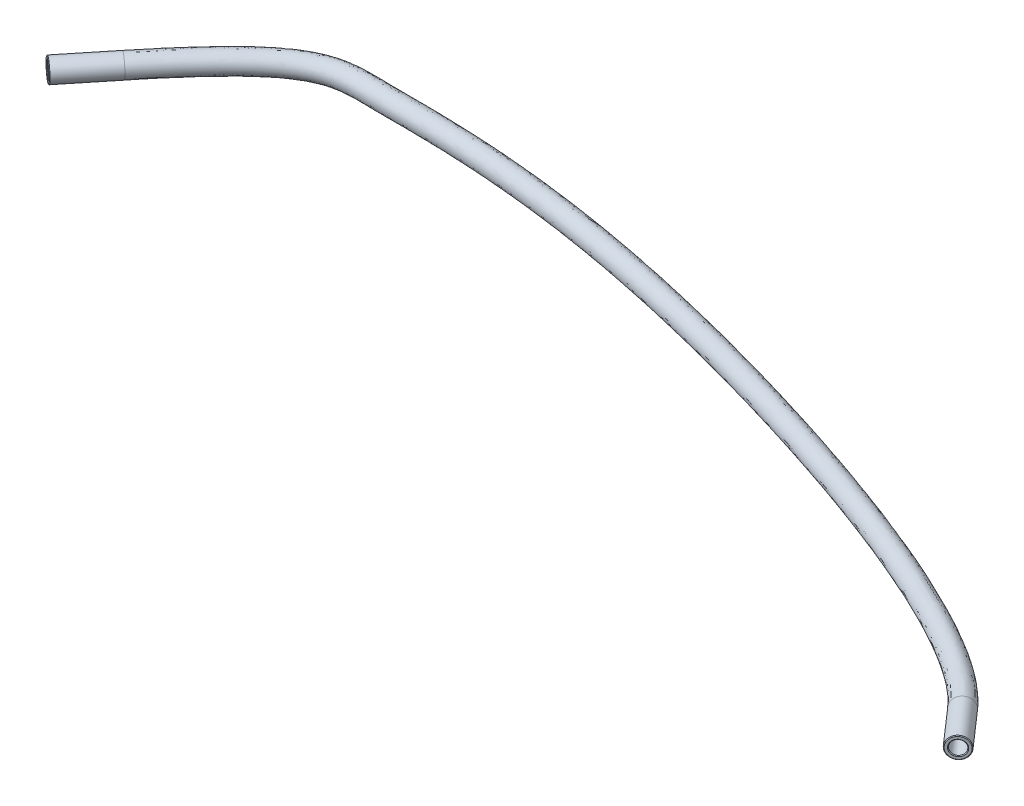
from build123d import *

# Parameters (mm, degrees)
SKETCH1_R     = 2
SKETCH1_R_2   = 1.3
CHAMFER1_SIZE = 0.127


with BuildPart() as part:
    # Sweep1: sweep along a curve in space
    with BuildLine() as sweep1_path:
        Line((-109.912579053, -99.5875, -21.924919528), (-116.326440239, -99.5875, -13.993817165))
        add(Edge.make_bspline(
            [(74.604127149, -99.6875, 3.918591429), (62.804964038, -99.6875, -9.55808219), (-32.990002224, -99.652202026, -42.829060997), (-83.325443001, -99.602202026, -40.268452954), (-93.662583417, -99.5875, -42.018958832), (-109.912579053, -99.5875, -21.924919528)],
            knots=[0, 0, 0, 0, 0.304238485, 0.705959482, 1, 1, 1, 1], degree=3))
        Line((80.664427015, -99.6875, 10.84049619), (74.604127149, -99.6875, 3.918591429))
    # Sketch1 → Sweep1 (sweep)
    with BuildSketch(Plane(origin=(35.697879774, 0, 40.773118402), x_dir=(-0.752380952, 0, 0.658728246), z_dir=(-0.658728246, 0, -0.752380952))):
        with Locations((-53.549437376, -99.6875)):
            Circle(SKETCH1_R)
        with Locations((-53.549437376, -99.6875)):
            Circle(SKETCH1_R_2, mode=Mode.SUBTRACT)
    sweep(path=sweep1_path.line)

    # Chamfer1
    chamfer1_edges = [part.edges().sort_by_distance(p)[0] for p in [
        (81.642522253, -99.6875, 9.98414947),
        (-117.337266625, -99.58636399, -14.81126975),
        (82.169188919, -99.6875, 9.523039698),
        (-117.881557756, -99.585752292, -15.251436526),
    ]]
    chamfer(chamfer1_edges, length=CHAMFER1_SIZE)


solid = part.part
